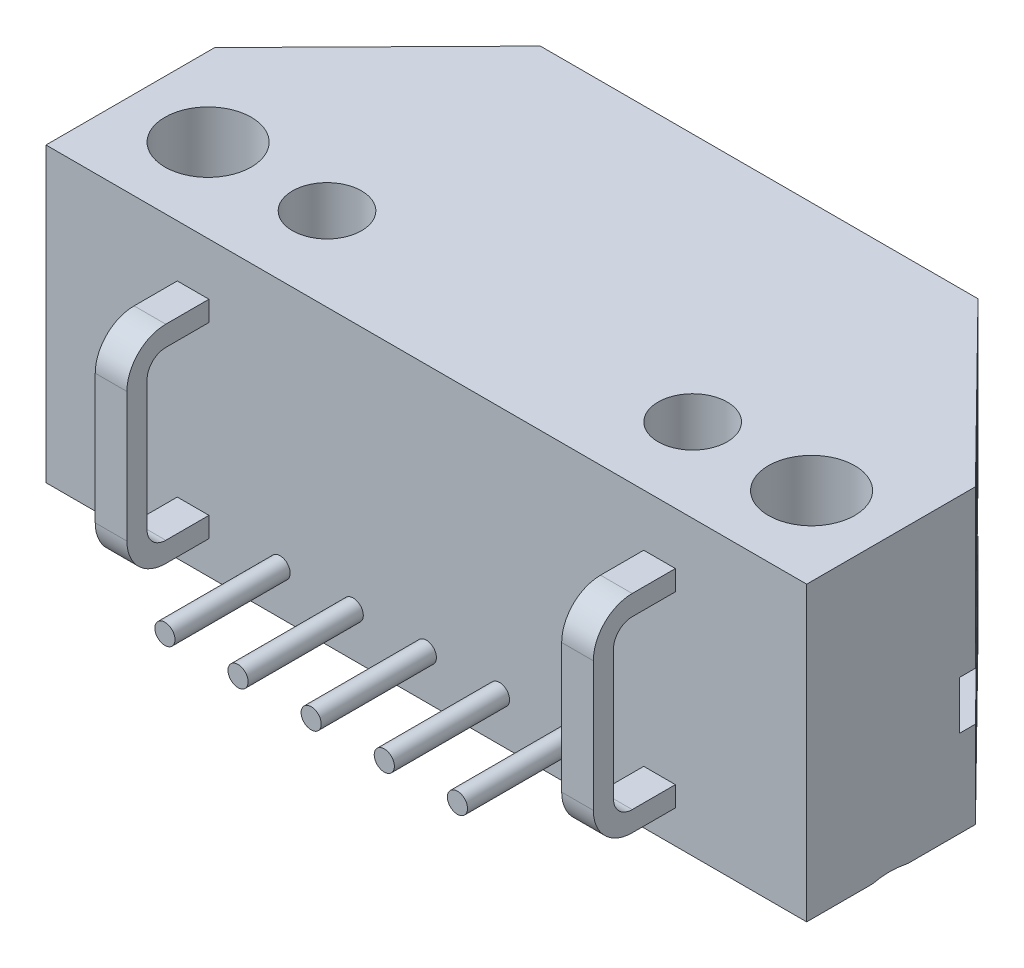
from build123d import *

# Parameters (mm, degrees)
AUFSATZ_LINEAR_AUSTRAGEN1_DEPTH                      = 6.74
AUFSATZ_LINEAR_AUSTRAGEN1_DEPTH_BACK                 = 3.42
SKIZZE1_R                                            = 1.385
SCHNITT_LINEAR_AUSTRAGEN1_DEPTH                      = 24.827593248
SCHNITT_LINEAR_AUSTRAGEN1_DEPTH_BACK                 = 24.827593248
SKIZZE2_W                                            = 16.035180953
SKIZZE2_H                                            = 1.68
SKIZZE3_R                                            = 1.2
SCHNITT_LINEAR_AUSTRAGEN2_DEPTH                      = 2.16
SKIZZE4_R                                            = 0.35
AUFSATZ_LINEAR_AUSTRAGEN2_DEPTH                      = 4
LINEAR_AUSTRAGEN_D_NN1_DEPTH                         = 0.55
FORMSENKUNG_F_R_M3_SENKSCHRAUBE_MIT_SCHL_D           = 3
FORMSENKUNG_F_R_M3_SENKSCHRAUBE_MIT_SCHL_DEPTH       = 11
FORMSENKUNG_F_R_M3_SENKSCHRAUBE_MIT_SCHL_CSINK_D     = 5.6
FORMSENKUNG_F_R_M3_SENKSCHRAUBE_MIT_SCHL_CSINK_ANGLE = 90
FORMSENKUNG_F_R_M3_SENKSCHRAUBE_MIT_SCHL_TIP         = 0.901290929


with BuildPart() as part:
    # Skizze1 → Aufsatz-Linear austragen1 (new, two sides: drawn at the far end of the back side and taken through both)
    with BuildSketch(Plane(origin=(0, 0, 0), x_dir=(1, 0, 0), z_dir=(0, 1, 0)).offset(-AUFSATZ_LINEAR_AUSTRAGEN1_DEPTH_BACK)):
        Polygon((-13.21, -18.65), (-13.21, -12.79), (-7.6, -7.09), (7.6, -7.09), (13.21, -12.79), (13.21, -18.65), align=None)
        with Locations((-10.48, -15.75)):
            Circle(SKIZZE1_R, mode=Mode.SUBTRACT)
        with Locations((10.48, -15.75)):
            Circle(SKIZZE1_R, mode=Mode.SUBTRACT)
    extrude(amount=AUFSATZ_LINEAR_AUSTRAGEN1_DEPTH + AUFSATZ_LINEAR_AUSTRAGEN1_DEPTH_BACK)

    # Skizze2 → Schnitt-Linear austragen1 (cut, two sides: drawn at the far end of the back side and taken through both)
    with BuildSketch(Plane(origin=(0, 0, 0), x_dir=(0, 0, -1), z_dir=(1, 0, 0)).offset(-SCHNITT_LINEAR_AUSTRAGEN1_DEPTH_BACK)):
        with Locations((-5.332409524, 0.44)):
            Rectangle(SKIZZE2_W, SKIZZE2_H)
    extrude(amount=SCHNITT_LINEAR_AUSTRAGEN1_DEPTH + SCHNITT_LINEAR_AUSTRAGEN1_DEPTH_BACK, mode=Mode.SUBTRACT)

    # Skizze3 → Schnitt-Linear austragen2 (cut)
    with BuildSketch(Plane(origin=(0, 6.74, 0), x_dir=(1, 0, 0), z_dir=(0, 1, 0))):
        with Locations((6.35, -15.75)):
            Circle(SKIZZE3_R)
        with Locations((-6.35, -15.75)):
            Circle(SKIZZE3_R)
    extrude(amount=-SCHNITT_LINEAR_AUSTRAGEN2_DEPTH, mode=Mode.SUBTRACT)

    # Skizze4 → Aufsatz-Linear austragen2 (add)
    with BuildSketch(Plane.XY.offset(18.65)):
        with Locations((0, -1.9)):
            Circle(SKIZZE4_R)
        with Locations((2.54, -1.9)):
            Circle(SKIZZE4_R)
        with Locations((5.08, -1.9)):
            Circle(SKIZZE4_R)
        with Locations((-2.54, -1.9)):
            Circle(SKIZZE4_R)
        with Locations((-5.08, -1.9)):
            Circle(SKIZZE4_R)
    extrude(amount=AUFSATZ_LINEAR_AUSTRAGEN2_DEPTH)

    # Skizze5 → Linear-Austragen-Dünn1 (add, symmetric)
    with BuildSketch(Plane(origin=(8.1, 0, 0), x_dir=(0, 0, -1), z_dir=(1, 0, 0))):
        with BuildLine():
            Line((-18.65, -1.57), (-20.15, -1.57))
            ThreePointArc((-20.15, -1.57), (-20.609619408, -1.379619408), (-20.8, -0.92))
            Line((-20.8, -0.92), (-20.8, 3.58))
            ThreePointArc((-20.8, 3.58), (-20.609619408, 4.039619408), (-20.15, 4.23))
            Line((-20.15, 4.23), (-18.65, 4.23))
            Line((-18.65, 4.23), (-18.65, 4.93))
            Line((-18.65, 4.93), (-20.15, 4.93))
            ThreePointArc((-20.15, 4.93), (-21.104594155, 4.534594155), (-21.5, 3.58))
            Line((-21.5, 3.58), (-21.5, -0.92))
            ThreePointArc((-21.5, -0.92), (-21.104594155, -1.874594155), (-20.15, -2.27))
            Line((-20.15, -2.27), (-18.65, -2.27))
            Line((-18.65, -2.27), (-18.65, -1.57))
        make_face()
    linear_austragen_d_nn1 = extrude(amount=LINEAR_AUSTRAGEN_D_NN1_DEPTH, both=True)

    # Spiegeln1: Linear-Austragen-Dünn1 across plane
    add(linear_austragen_d_nn1.mirror(Plane(origin=(0, 0, 0), x_dir=(0, 0, 1), z_dir=(1, 0, 0))))

    # Formsenkung für M3 Senkschraube mit Schlitz/Kreuzschlitz1
    with Locations(Plane(origin=(0, -3.42, 0), x_dir=(-1, 0, 0), z_dir=(0, -1, 0))):
        with Locations((-10.48, -15.75), (10.48, -15.75)):
            CounterSinkHole(FORMSENKUNG_F_R_M3_SENKSCHRAUBE_MIT_SCHL_D / 2, FORMSENKUNG_F_R_M3_SENKSCHRAUBE_MIT_SCHL_CSINK_D / 2, depth=FORMSENKUNG_F_R_M3_SENKSCHRAUBE_MIT_SCHL_DEPTH, counter_sink_angle=FORMSENKUNG_F_R_M3_SENKSCHRAUBE_MIT_SCHL_CSINK_ANGLE)
            with Locations((0, 0, -(FORMSENKUNG_F_R_M3_SENKSCHRAUBE_MIT_SCHL_DEPTH + FORMSENKUNG_F_R_M3_SENKSCHRAUBE_MIT_SCHL_TIP / 2))):  # 118° drill point
                Cone(0, FORMSENKUNG_F_R_M3_SENKSCHRAUBE_MIT_SCHL_D / 2, FORMSENKUNG_F_R_M3_SENKSCHRAUBE_MIT_SCHL_TIP, mode=Mode.SUBTRACT)


solid = part.part
